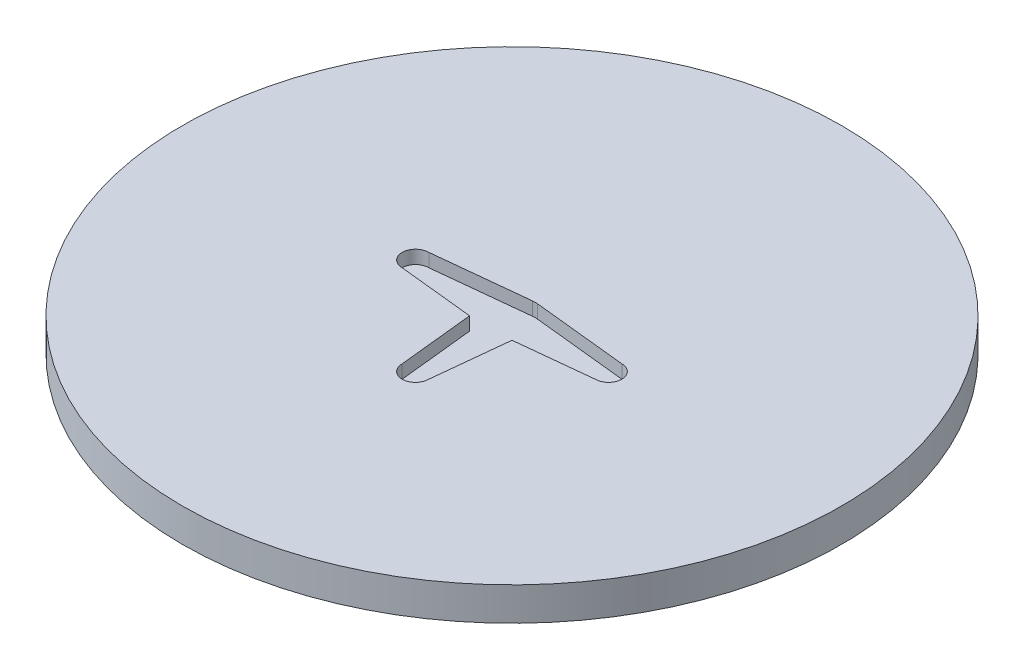
from build123d import *

# Parameters (mm, degrees)
SKETCH1_R           = 49.5
BOSS_EXTRUDE1_DEPTH = 5
CUT_EXTRUDE1_DEPTH  = 2
CUT_EXTRUDE2_DEPTH  = 2


with BuildPart() as part:
    # Sketch1 → Boss-Extrude1 (new body)
    with BuildSketch(Plane(origin=(0, 0, 0), x_dir=(1, 0, 0), z_dir=(0, 1, 0))):
        Circle(SKETCH1_R)
    extrude(amount=BOSS_EXTRUDE1_DEPTH)

    # Sketch2 → Cut-Extrude1 (cut)
    with BuildSketch(Plane(origin=(0, 5, 0), x_dir=(1, 0, 0), z_dir=(0, 1, 0))):
        with BuildLine():
            Line((14.5, 2), (0.364696883, 3.480947599))
            ThreePointArc((0.364696883, 3.480947599), (0, 3.5), (-0.364696883, 3.480947599))
            Line((-0.364696883, 3.480947599), (-14.5, 2))
            ThreePointArc((-14.5, 2), (-16.5, 0), (-14.5, -2))
            Line((-14.5, -2), (-3.185421861, -3.185421861))
            Line((-3.185421861, -3.185421861), (-2, -14.5))
            ThreePointArc((-2, -14.5), (0, -16.5), (2, -14.5))
            Line((2, -14.5), (3.185421861, -3.185421861))
            Line((3.185421861, -3.185421861), (14.5, -2))
            ThreePointArc((14.5, -2), (16.5, 0), (14.5, 2))
        make_face()
    extrude(amount=-CUT_EXTRUDE1_DEPTH, mode=Mode.SUBTRACT)

    # Sketch3 → Cut-Extrude2 (cut)
    with BuildSketch(Plane.XZ):
        with BuildLine():
            add(Edge.make_bspline(
                [(7.183697139, 7.183697139), (0, 87.002554241), (-7.183697139, 7.183697139)],
                knots=[1.862253121, 1.862253121, 1.862253121, 4.420932186, 4.420932186, 4.420932186], degree=2, weights=[1, 0.287347886, 1]))
            add(Edge.make_bspline(
                [(-7.183697139, 7.183697139), (-87.002554241, 0), (-7.183697139, -7.183697139)],
                knots=[5.003845775, 5.003845775, 5.003845775, 7.562524839, 7.562524839, 7.562524839], degree=2, weights=[1, 0.287347886, 1]))
            add(Edge.make_bspline(
                [(-7.183697139, -7.183697139), (0, -87.002554241), (7.183697139, -7.183697139)],
                knots=[5.003845775, 5.003845775, 5.003845775, 7.562524839, 7.562524839, 7.562524839], degree=2, weights=[1, 0.287347886, 1]))
            add(Edge.make_bspline(
                [(7.183697139, -7.183697139), (87.002554241, 0), (7.183697139, 7.183697139)],
                knots=[1.862253121, 1.862253121, 1.862253121, 4.420932186, 4.420932186, 4.420932186], degree=2, weights=[1, 0.287347886, 1]))
        make_face()
    extrude(amount=-CUT_EXTRUDE2_DEPTH, mode=Mode.SUBTRACT)


solid = part.part
